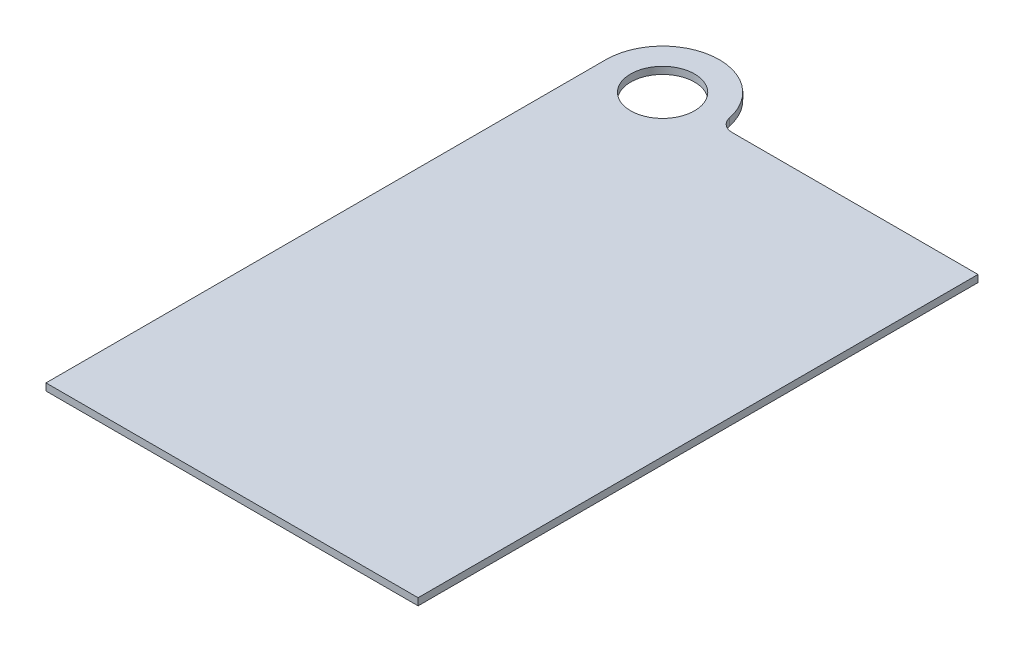
from build123d import *

# Parameters (mm, degrees)
SKETCH1_R           = 14.3129
BOSS_EXTRUDE1_DEPTH = 3.175
FILLET2_R           = 6.35


with BuildPart() as part:
    # Sketch1 → Boss-Extrude1 (new body)
    with BuildSketch(Plane(origin=(0, 0, 0), x_dir=(1, 0, 0), z_dir=(0, 1, 0))):
        with BuildLine():
            Line((-25.4, 0), (-25.4, -250.825))
            Line((-25.4, -250.825), (141.2875, -250.825))
            Line((141.2875, -250.825), (141.2875, 0))
            Line((141.2875, 0), (25.4, 0))
            ThreePointArc((25.4, 0), (0, 25.4), (-25.4, 0))
        make_face()
        Circle(SKETCH1_R, mode=Mode.SUBTRACT)
    extrude(amount=BOSS_EXTRUDE1_DEPTH)

    # Fillet2
    fillet2_edges = [part.edges().sort_by_distance(p)[0] for p in [
        (25.4, 1.5875, 0),
    ]]
    fillet(fillet2_edges, radius=FILLET2_R)


solid = part.part
